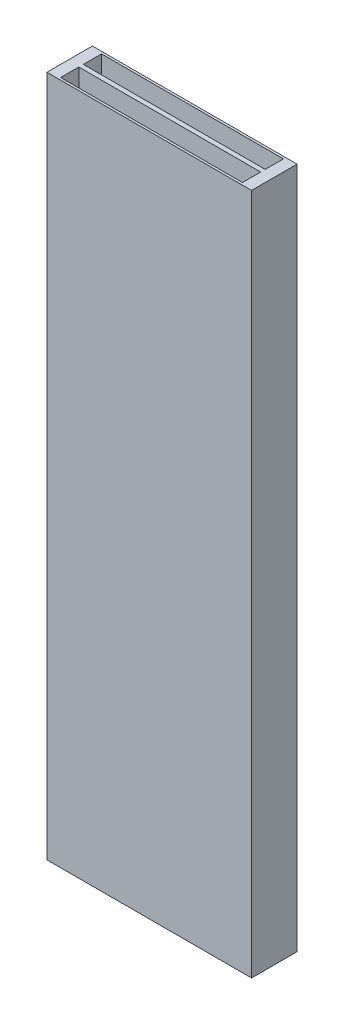
from build123d import *

# Parameters (mm, degrees)
SKETCH1_W           = 9
SKETCH1_H           = 2
BOSS_EXTRUDE1_DEPTH = 15
CUT_EXTRUDE1_START  = -31
SKETCH2_W           = 8
SKETCH2_H           = 0.8
CUT_EXTRUDE1_DEPTH  = 32


with BuildPart() as part:
    # Sketch1 → Boss-Extrude1 (new body, symmetric)
    with BuildSketch(Plane(origin=(0, 0, 0), x_dir=(1, 0, 0), z_dir=(0, 1, 0))):
        Rectangle(SKETCH1_W, SKETCH1_H)
    extrude(amount=BOSS_EXTRUDE1_DEPTH, both=True)

    # Sketch2 → Cut-Extrude1 (cut)
    with BuildSketch(Plane(origin=(0, 15, 0), x_dir=(1, 0, 0), z_dir=(0, 1, 0)).offset(CUT_EXTRUDE1_START)):
        with Locations((0, 0.5)):
            Rectangle(SKETCH2_W, SKETCH2_H)
    cut_extrude1 = extrude(amount=CUT_EXTRUDE1_DEPTH, mode=Mode.SUBTRACT)

    # Mirror1: Cut-Extrude1 across plane
    add(cut_extrude1.mirror(Plane.XY), mode=Mode.SUBTRACT)


solid = part.part
